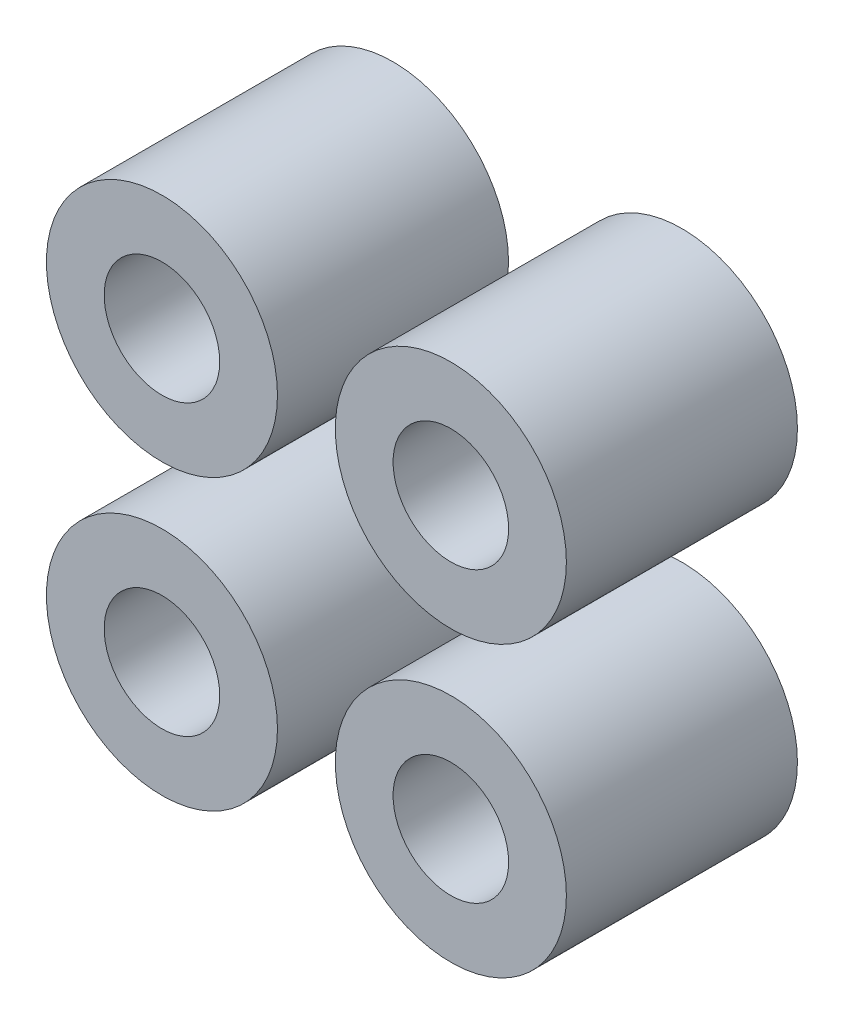
from build123d import *

# Parameters (mm, degrees)
SKETCH2_R             = 3
SKETCH2_R_2           = 1.5
BOSS_EXTRUDE1_DEPTH   = 6
BOSS_EXTRUDE1_2_DEPTH = 6
BOSS_EXTRUDE1_3_DEPTH = 6
BOSS_EXTRUDE1_4_DEPTH = 6


with BuildPart() as part:
    # Sketch2 → Boss-Extrude1 (new body)
    with BuildSketch(Plane.XY):
        with Locations((-3.751201474, 3.751201474)):
            Circle(SKETCH2_R)
        with Locations((-3.751201474, 3.751201474)):
            Circle(SKETCH2_R_2, mode=Mode.SUBTRACT)
    extrude(amount=BOSS_EXTRUDE1_DEPTH)


with BuildPart() as body_2:
    # Sketch2 → Boss-Extrude1 2 (new body)
    with BuildSketch(Plane.XY):
        with Locations((3.751201474, 3.751201474)):
            Circle(SKETCH2_R)
        with Locations((3.751201474, 3.751201474)):
            Circle(SKETCH2_R_2, mode=Mode.SUBTRACT)
    extrude(amount=BOSS_EXTRUDE1_2_DEPTH)


with BuildPart() as body_3:
    # Sketch2 → Boss-Extrude1 3 (new body)
    with BuildSketch(Plane.XY):
        with Locations((3.751201474, -3.751201474)):
            Circle(SKETCH2_R)
        with Locations((3.751201474, -3.751201474)):
            Circle(SKETCH2_R_2, mode=Mode.SUBTRACT)
    extrude(amount=BOSS_EXTRUDE1_3_DEPTH)


with BuildPart() as body_4:
    # Sketch2 → Boss-Extrude1 4 (new body)
    with BuildSketch(Plane.XY):
        with Locations((-3.751201474, -3.751201474)):
            Circle(SKETCH2_R)
        with Locations((-3.751201474, -3.751201474)):
            Circle(SKETCH2_R_2, mode=Mode.SUBTRACT)
    extrude(amount=BOSS_EXTRUDE1_4_DEPTH)


solid = Compound([part.part, body_2.part, body_3.part, body_4.part])
